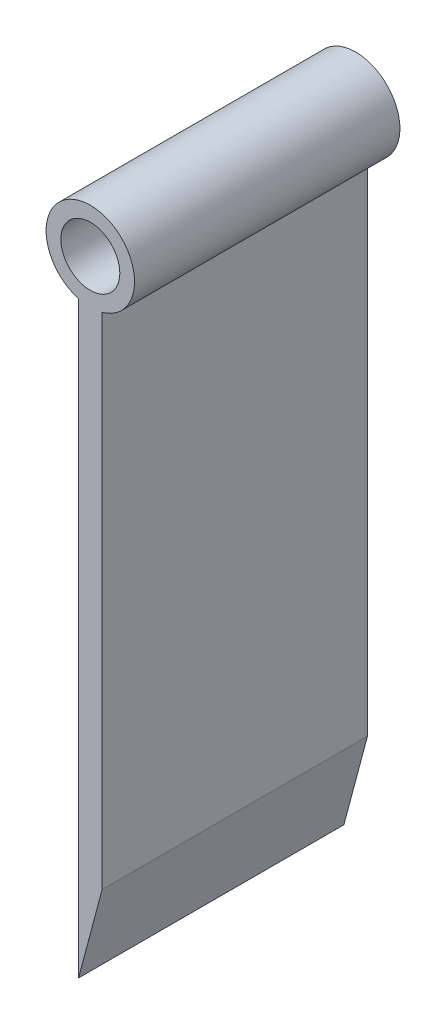
from build123d import *

# Parameters (mm, degrees)
CROQUIS1_R              = 3.75
CROQUIS1_R_2            = 2.5
SALIENTE_EXTRUIR1_DEPTH = 22.5


with BuildPart() as part:
    # Croquis1 → Saliente-Extruir1 (new body)
    with BuildSketch(Plane.XY):
        with Locations((1, 53.5)):
            Circle(CROQUIS1_R)
        with Locations((1, 53.5)):
            Circle(CROQUIS1_R_2, mode=Mode.SUBTRACT)
        with BuildLine():
            Line((0, 49.885791926), (0, 0))
            Line((0, 0), (2, 7.5))
            Line((2, 7.5), (2, 49.885791926))
            ThreePointArc((2, 49.885791926), (1, 49.75), (0, 49.885791926))
        make_face()
    extrude(amount=SALIENTE_EXTRUIR1_DEPTH)


solid = part.part
